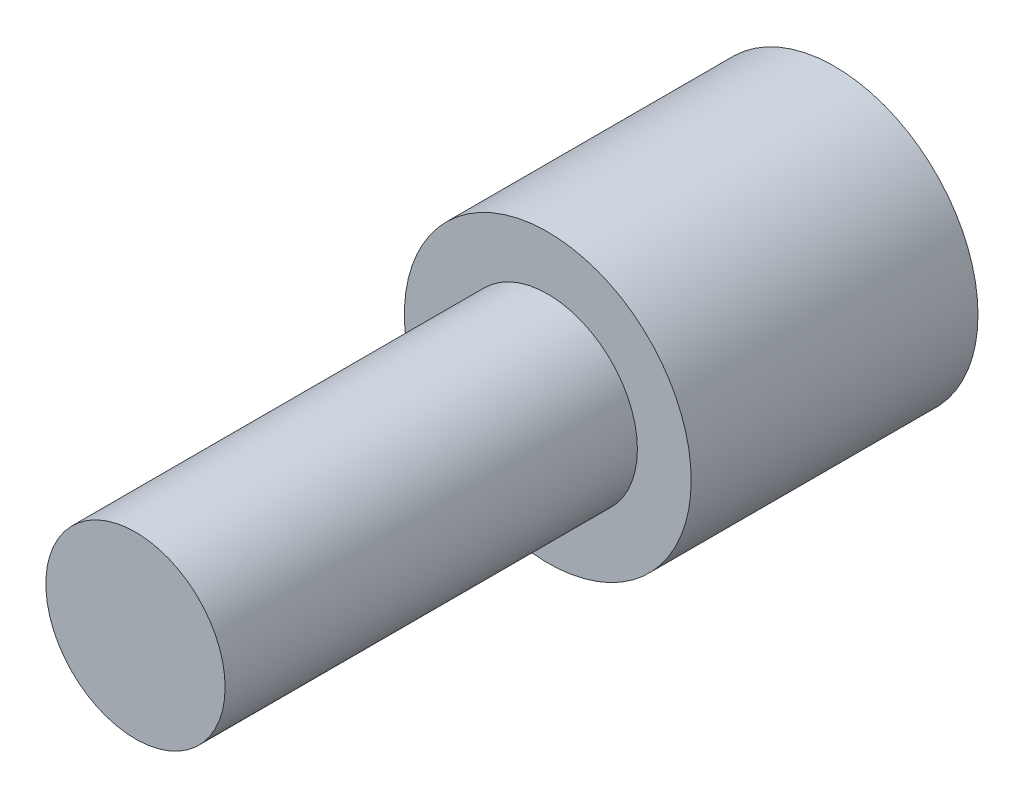
from build123d import *

# Parameters (mm, degrees)
SKETCH2_R           = 20
BOSS_EXTRUDE1_DEPTH = 40
SKETCH3_R           = 12.5
BOSS_EXTRUDE2_DEPTH = 57.5


with BuildPart() as part:
    # Sketch2 → Boss-Extrude1 (new body)
    with BuildSketch(Plane.XY):
        Circle(SKETCH2_R)
    extrude(amount=BOSS_EXTRUDE1_DEPTH)

    # Sketch3 → Boss-Extrude2 (add)
    with BuildSketch(Plane.XY.offset(40)):
        Circle(SKETCH3_R)
    extrude(amount=BOSS_EXTRUDE2_DEPTH)


solid = part.part
